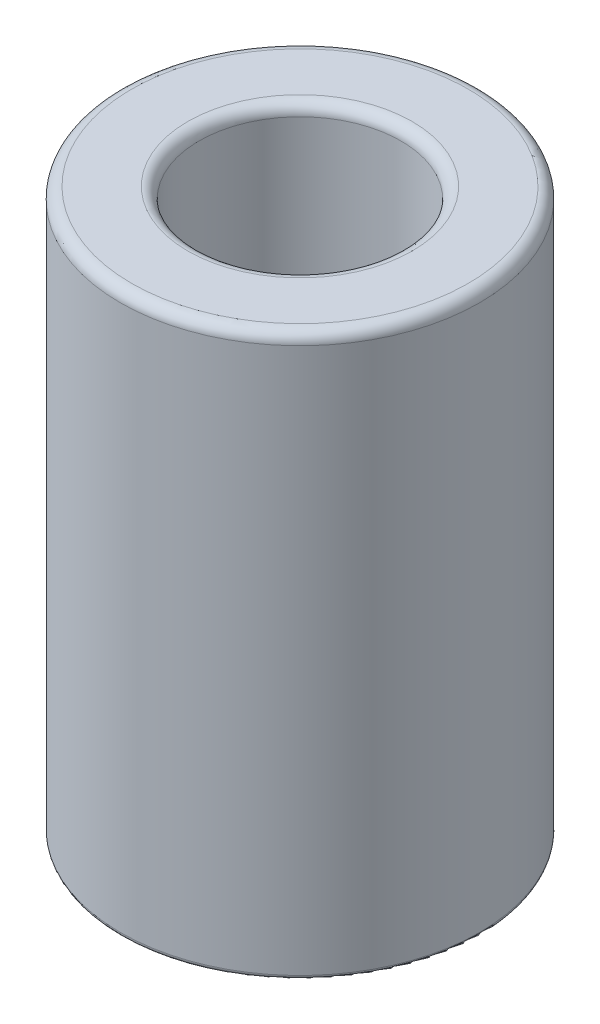
from build123d import *

# Parameters (mm, degrees)
SKETCH2_R           = 8
BOSS_EXTRUDE1_DEPTH = 25
SKETCH3_R           = 4.5
CUT_EXTRUDE1_DEPTH  = 15.13
SKETCH4_R           = 2.5
CUT_EXTRUDE2_DEPTH  = 10.87
FILLET1_R           = 0.5
FILLET2_R           = 0.5
CHAMFER1_SIZE       = 0.5
FILLET3_R           = 0.2


with BuildPart() as part:
    # Sketch2 → Boss-Extrude1 (new body)
    with BuildSketch(Plane(origin=(0, 0, 0), x_dir=(1, 0, 0), z_dir=(0, 1, 0))):
        Circle(SKETCH2_R)
    extrude(amount=BOSS_EXTRUDE1_DEPTH)

    # Sketch3 → Cut-Extrude1 (cut)
    with BuildSketch(Plane(origin=(0, 25, 0), x_dir=(1, 0, 0), z_dir=(0, 1, 0))):
        Circle(SKETCH3_R)
    extrude(amount=-CUT_EXTRUDE1_DEPTH, mode=Mode.SUBTRACT)

    # Sketch4 → Cut-Extrude2 (cut, through all)
    with BuildSketch(Plane(origin=(0, 9.87, 0), x_dir=(1, 0, 0), z_dir=(0, 1, 0))):
        Circle(SKETCH4_R)
    extrude(amount=-CUT_EXTRUDE2_DEPTH, mode=Mode.SUBTRACT)

    # Fillet1
    fillet1_edges = [part.edges().sort_by_distance(p)[0] for p in [
        (-8, 25, 0),
    ]]
    fillet(fillet1_edges, radius=FILLET1_R)

    # Fillet2
    fillet2_edges = [part.edges().sort_by_distance(p)[0] for p in [
        (-4.5, 25, 0),
    ]]
    fillet(fillet2_edges, radius=FILLET2_R)

    # Chamfer1
    chamfer1_edges = [part.edges().sort_by_distance(p)[0] for p in [
        (-2.5, 0, 0),
        (-2.5, 9.87, 0),
    ]]
    chamfer(chamfer1_edges, length=CHAMFER1_SIZE)

    # Fillet3
    fillet3_edges = [part.edges().sort_by_distance(p)[0] for p in [
        (-8, 0, 0),
    ]]
    fillet(fillet3_edges, radius=FILLET3_R)


solid = part.part
